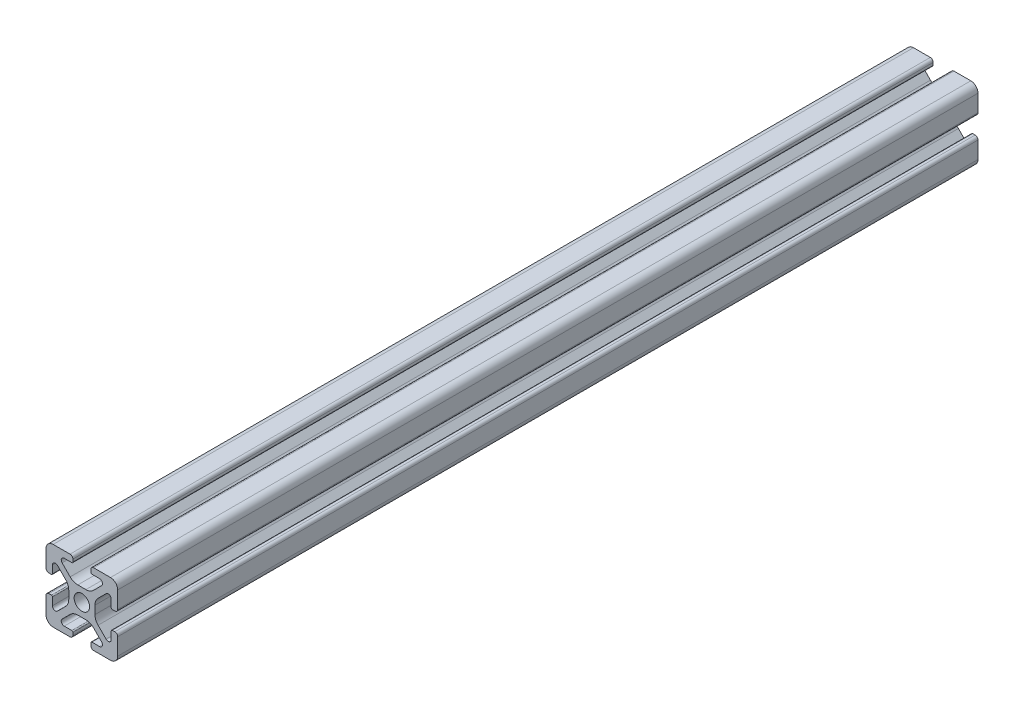
from build123d import *

# Parameters (mm, degrees)
SKETCH4_W              = 20
SKETCH4_H              = 20
BODY_DEPTH             = 240
SKETCH16_OUTSIDE_W     = 70.332
SKETCH16_OUTSIDE_H     = 70.332
SKETCH16_OUTSIDE_R     = 2.15
CUT_PROFILE_DEPTH      = 26
CUT_PROFILE_DEPTH_BACK = 216


with BuildPart() as part:
    # Sketch4 → Body (new body)
    with BuildSketch(Plane.XY.offset(25)):
        Rectangle(SKETCH4_W, SKETCH4_H)
    extrude(amount=-BODY_DEPTH)

    # Sketch16 outside → Cut-Profile (cut, two sides)
    with BuildSketch(Plane.XY) as cut_profile_sk:
        Rectangle(SKETCH16_OUTSIDE_W, SKETCH16_OUTSIDE_H)
        with BuildLine():
            Line((4.917588389, -8.199999991), (2.799999989, -8.199999991))
            ThreePointArc((2.799999989, -8.199999991), (2.587867955, -8.287867957), (2.499999989, -8.499999991))
            Line((2.499999989, -8.499999991), (2.499999989, -9.199999991))
            ThreePointArc((2.499999989, -9.199999991), (2.734314564, -9.765685416), (3.299999989, -9.999999991))
            Line((3.299999989, -9.999999991), (7.999999989, -9.999999991))
            ThreePointArc((7.999999989, -9.999999991), (9.414213552, -9.414213554), (9.999999989, -7.999999991))
            Line((9.999999989, -7.999999991), (9.999999989, -3.299999991))
            ThreePointArc((9.999999989, -3.299999991), (9.765685414, -2.734314566), (9.199999989, -2.499999991))
            Line((9.199999989, -2.499999991), (8.499999989, -2.499999991))
            ThreePointArc((8.499999989, -2.499999991), (8.287867955, -2.587867957), (8.199999989, -2.799999991))
            Line((8.199999989, -2.799999991), (8.199999989, -4.917588391))
            ThreePointArc((8.199999989, -4.917588391), (7.686138511, -5.686636441), (6.778984485, -5.506192286))
            Line((6.778984485, -5.506192286), (4.528679645, -3.255887446))
            ThreePointArc((4.528679645, -3.255887446), (3.878361392, -2.282617401), (3.64999999, -1.134567106))
            Line((3.64999999, -1.134567106), (3.64999999, 1.134567104))
            ThreePointArc((3.64999999, 1.134567104), (3.878361393, 2.282617402), (4.528679647, 3.255887448))
            Line((4.528679647, 3.255887448), (6.778984487, 5.506192288))
            ThreePointArc((6.778984487, 5.506192288), (7.686138506, 5.686636442), (8.199999981, 4.917588398))
            Line((8.199999981, 4.917588398), (8.199999981, 2.799999998))
            ThreePointArc((8.199999981, 2.799999998), (8.287867946, 2.587867964), (8.499999981, 2.499999998))
            Line((8.499999981, 2.499999998), (9.199999981, 2.499999998))
            ThreePointArc((9.199999981, 2.499999998), (9.765685406, 2.734314573), (9.999999981, 3.299999998))
            Line((9.999999981, 3.299999998), (9.999999981, 7.999999998))
            ThreePointArc((9.999999981, 7.999999998), (9.414213543, 9.41421356), (7.999999981, 9.999999998))
            Line((7.999999981, 9.999999998), (3.299999981, 9.999999998))
            ThreePointArc((3.299999981, 9.999999998), (2.734314556, 9.765685423), (2.499999981, 9.199999998))
            Line((2.499999981, 9.199999998), (2.499999981, 8.499999998))
            ThreePointArc((2.499999981, 8.499999998), (2.587867946, 8.287867964), (2.799999981, 8.199999998))
            Line((2.799999981, 8.199999998), (4.917588381, 8.199999998))
            ThreePointArc((4.917588381, 8.199999998), (5.68663643, 7.68613852), (5.506192275, 6.778984494))
            Line((5.506192275, 6.778984494), (3.255887435, 4.528679654))
            ThreePointArc((3.255887435, 4.528679654), (2.28261739, 3.878361401), (1.134567095, 3.649999999))
            Line((1.134567095, 3.649999999), (-1.134567115, 3.649999999))
            ThreePointArc((-1.134567115, 3.649999999), (-2.282617412, 3.878361401), (-3.255887459, 4.528679655))
            Line((-3.255887459, 4.528679655), (-5.506192299, 6.778984495))
            ThreePointArc((-5.506192299, 6.778984495), (-5.686636452, 7.686138515), (-4.917588409, 8.199999989))
            Line((-4.917588409, 8.199999989), (-2.800000009, 8.199999989))
            ThreePointArc((-2.800000009, 8.199999989), (-2.587867974, 8.287867955), (-2.500000009, 8.499999989))
            Line((-2.500000009, 8.499999989), (-2.500000009, 9.199999989))
            ThreePointArc((-2.500000009, 9.199999989), (-2.734314584, 9.765685414), (-3.300000009, 9.999999989))
            Line((-3.300000009, 9.999999989), (-8.000000009, 9.999999989))
            ThreePointArc((-8.000000009, 9.999999989), (-9.414213571, 9.414213552), (-10.000000009, 7.999999989))
            Line((-10.000000009, 7.999999989), (-10.000000009, 3.299999989))
            ThreePointArc((-10.000000009, 3.299999989), (-9.765685434, 2.734314564), (-9.200000009, 2.499999989))
            Line((-9.200000009, 2.499999989), (-8.500000009, 2.499999989))
            ThreePointArc((-8.500000009, 2.499999989), (-8.287867974, 2.587867955), (-8.200000009, 2.799999989))
            Line((-8.200000009, 2.799999989), (-8.200000009, 4.917588389))
            ThreePointArc((-8.200000009, 4.917588389), (-7.686138531, 5.686636438), (-6.778984504, 5.506192284))
            Line((-6.778984504, 5.506192284), (-4.528679664, 3.255887444))
            ThreePointArc((-4.528679664, 3.255887444), (-3.878361412, 2.282617399), (-3.650000009, 1.134567104))
            Line((-3.650000009, 1.134567104), (-3.650000009, -1.134567106))
            ThreePointArc((-3.650000009, -1.134567106), (-3.878361412, -2.282617404), (-4.528679666, -3.25588745))
            Line((-4.528679666, -3.25588745), (-6.778984506, -5.50619229))
            ThreePointArc((-6.778984506, -5.50619229), (-7.686138526, -5.686636444), (-8.2, -4.9175884))
            Line((-8.2, -4.9175884), (-8.2, -2.8))
            ThreePointArc((-8.2, -2.8), (-8.287867966, -2.587867966), (-8.5, -2.5))
            Line((-8.5, -2.5), (-9.2, -2.5))
            ThreePointArc((-9.2, -2.5), (-9.765685425, -2.734314575), (-10, -3.3))
            Line((-10, -3.3), (-10, -8))
            ThreePointArc((-10, -8), (-9.414213562, -9.414213562), (-8, -10))
            Line((-8, -10), (-3.3, -10))
            ThreePointArc((-3.3, -10), (-2.734314575, -9.765685425), (-2.5, -9.2))
            Line((-2.5, -9.2), (-2.5, -8.5))
            ThreePointArc((-2.5, -8.5), (-2.587867966, -8.287867966), (-2.8, -8.2))
            Line((-2.8, -8.2), (-4.9175884, -8.2))
            ThreePointArc((-4.9175884, -8.2), (-5.686636449, -7.686138522), (-5.506192294, -6.778984496))
            Line((-5.506192294, -6.778984496), (-3.255887454, -4.528679656))
            ThreePointArc((-3.255887454, -4.528679656), (-2.282617409, -3.878361403), (-1.134567114, -3.650000001))
            Line((-1.134567114, -3.650000001), (1.134567096, -3.650000001))
            ThreePointArc((1.134567096, -3.650000001), (2.282617393, -3.878361403), (3.255887439, -4.528679657))
            Line((3.255887439, -4.528679657), (5.506192279, -6.778984497))
            ThreePointArc((5.506192279, -6.778984497), (5.686636433, -7.686138517), (4.917588389, -8.199999991))
        make_face(mode=Mode.SUBTRACT)
        Circle(SKETCH16_OUTSIDE_R)
    extrude(amount=CUT_PROFILE_DEPTH, mode=Mode.SUBTRACT)
    extrude(cut_profile_sk.sketch, amount=-CUT_PROFILE_DEPTH_BACK, mode=Mode.SUBTRACT)


solid = part.part
